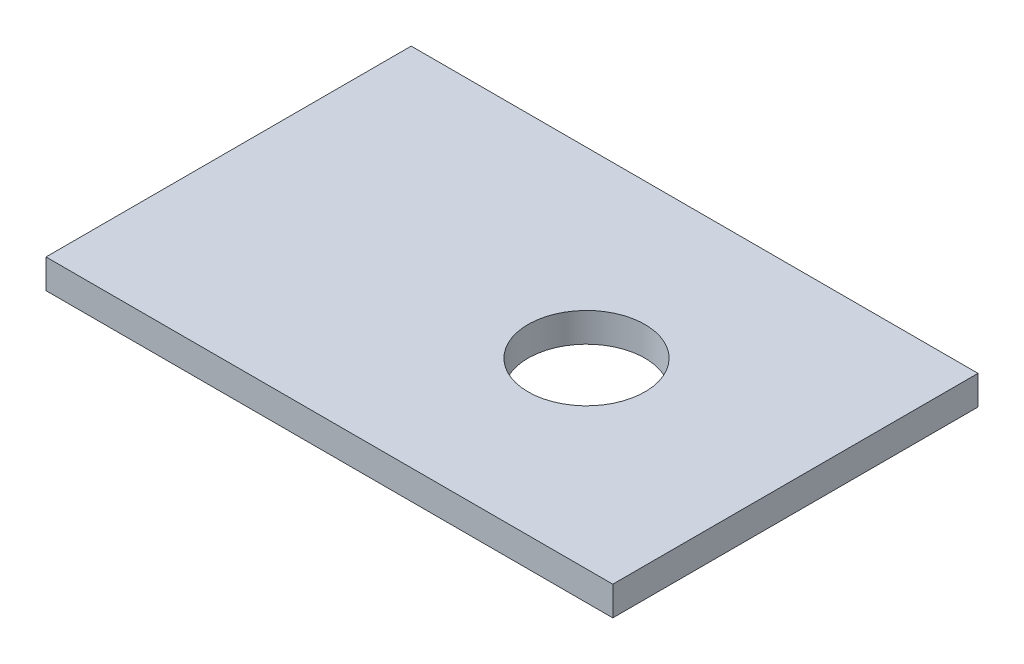
from build123d import *

# Parameters (mm, degrees)
SKETCH2_W           = 38.8
SKETCH2_H           = 25
BOSS_EXTRUDE1_DEPTH = 2
SKETCH3_R           = 4
CUT_EXTRUDE1_DEPTH  = 3


with BuildPart() as part:
    # Sketch2 → Boss-Extrude1 (new body)
    with BuildSketch(Plane(origin=(0, 0, 0), x_dir=(1, 0, 0), z_dir=(0, 1, 0))):
        Rectangle(SKETCH2_W, SKETCH2_H)
    extrude(amount=BOSS_EXTRUDE1_DEPTH)

    # Sketch3 → Cut-Extrude1 (cut, through all)
    with BuildSketch(Plane(origin=(0, 2, 0), x_dir=(1, 0, 0), z_dir=(0, 1, 0))):
        with Locations((5.1, 0)):
            Circle(SKETCH3_R)
    extrude(amount=-CUT_EXTRUDE1_DEPTH, mode=Mode.SUBTRACT)


solid = part.part
